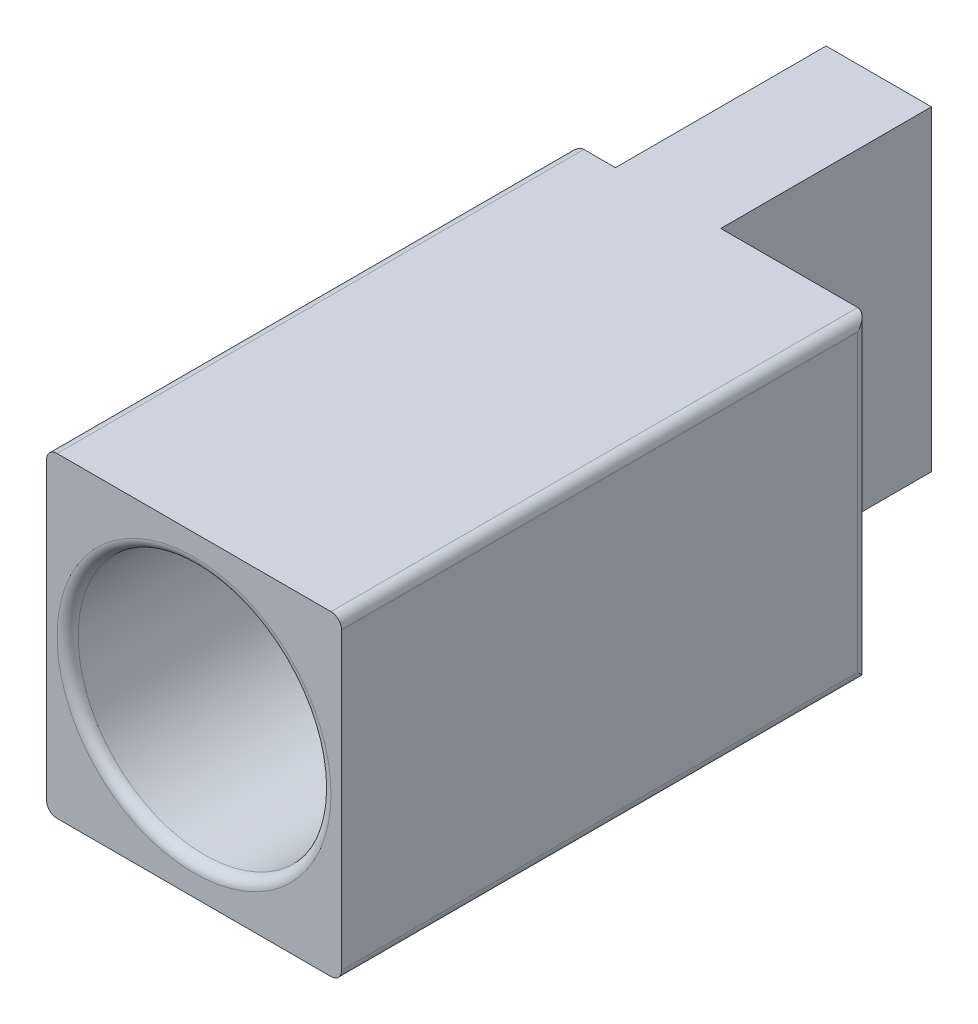
from build123d import *

# Parameters (mm, degrees)
SKETCH_1_W             = 14
SKETCH_1_H             = 15
EXTRUDE_1_DEPTH        = 35
SKETCH_2_R             = 6
CUT_EXTRUDE_1_DEPTH    = 15
CUT_EXTRUDE_2_REACH    = 17
SKETCH_3_W             = 2
SKETCH_3_H             = 10
SKETCH_3_W_2           = 7
HOLE_WIZARD_M4_1_D     = 3.3
HOLE_WIZARD_M4_1_DEPTH = 5
SKETCH_4_R             = 4
CUT_EXTRUDE_3_DEPTH    = 1
FILLET_1_R             = 0.5


with BuildPart() as part:
    # 草图1 → 凸台-拉伸1 (new body)
    with BuildSketch(Plane.XY):
        with Locations((7, -7.5)):
            Rectangle(SKETCH_1_W, SKETCH_1_H)
    extrude(amount=EXTRUDE_1_DEPTH)

    # 草图2 → 切除-拉伸1 (cut)
    with BuildSketch(Plane.XY.offset(35)):
        with Locations((7, -7.5)):
            Circle(SKETCH_2_R)
    extrude(amount=-CUT_EXTRUDE_1_DEPTH, mode=Mode.SUBTRACT)

    # 草图3 → 切除-拉伸2 (cut, up to next)
    with BuildSketch(Plane.XZ.offset(15), mode=Mode.PRIVATE) as cut_extrude_2_sk1:
        with Locations((1, 5)):
            Rectangle(SKETCH_3_W, SKETCH_3_H)
    cut_extrude_2_tool1 = extrude(cut_extrude_2_sk1.sketch, amount=-CUT_EXTRUDE_2_REACH, mode=Mode.PRIVATE) & part.part
    add(cut_extrude_2_tool1.solids().sort_by_distance((1, -15, 5))[0], mode=Mode.SUBTRACT)
    # 草图3 → 切除-拉伸2 (cut, up to next)
    with BuildSketch(Plane.XZ.offset(15), mode=Mode.PRIVATE) as cut_extrude_2_sk2:
        with Locations((10.5, 5)):
            Rectangle(SKETCH_3_W_2, SKETCH_3_H)
    cut_extrude_2_tool2 = extrude(cut_extrude_2_sk2.sketch, amount=-CUT_EXTRUDE_2_REACH, mode=Mode.PRIVATE) & part.part
    add(cut_extrude_2_tool2.solids().sort_by_distance((10.5, -15, 5))[0], mode=Mode.SUBTRACT)

    # M4 螺纹孔1
    with Locations(Plane.ZY.offset(-2)):
        with Locations((5, -7.5)):
            Hole(HOLE_WIZARD_M4_1_D / 2, depth=HOLE_WIZARD_M4_1_DEPTH)

    # 草图4 → 切除-拉伸3 (cut)
    with BuildSketch(Plane.ZY.offset(-2)):
        with Locations((5, -7.5)):
            Circle(SKETCH_4_R)
    extrude(amount=-CUT_EXTRUDE_3_DEPTH, mode=Mode.SUBTRACT)

    # 圆角1
    fillet_1_edges = [part.edges().sort_by_distance(p)[0] for p in [
        (1, -7.5, 20),
        (1, -7.5, 35),
        (0, -7.5, 10),
        (14, -7.5, 10),
        (0, 0, 22.5),
        (14, 0, 22.5),
        (14, -15, 22.5),
        (0, -15, 22.5),
    ]]
    fillet(fillet_1_edges, radius=FILLET_1_R)


solid = part.part
